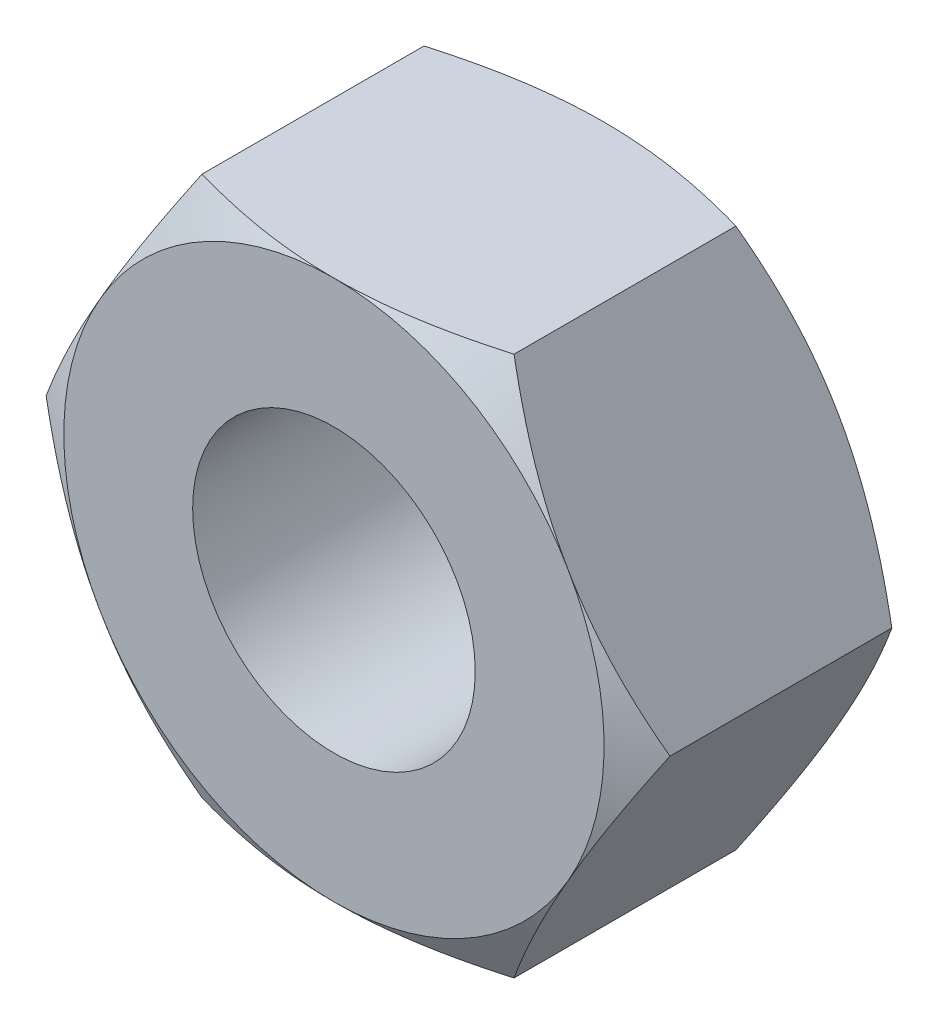
from build123d import *

# Parameters (mm, degrees)
BOSS_EXTRUDE1_DEPTH = 6.5
M8_TAPPED_HOLE1_D   = 6.8


with BuildPart() as part:
    # Sketch1 → Boss-Extrude1 (new body)
    with BuildSketch(Plane.XY):
        Polygon((3.75277675, -6.5), (7.505553499, 0), (3.75277675, 6.5), (-3.75277675, 6.5), (-7.505553499, 0), (-3.75277675, -6.5), align=None)
    extrude(amount=BOSS_EXTRUDE1_DEPTH)

    # Sketch3 → Cut-Revolve1 (revolve, cut)
    with BuildSketch(Plane(origin=(0, 0, 0), x_dir=(0, 0, -1), z_dir=(1, 0, 0))):
        Polygon((-1.711637245, 9.464642673), (0, 6.5), (0, 9.464642673), align=None)
        Polygon((-6.5, 6.5), (-6.5, 9.37662807), (-4.839178009, 9.37662807), align=None)
    revolve(axis=Axis((0, 0, 0), (0, 0, -1)), mode=Mode.SUBTRACT)

    # M8 Tapped Hole1 (through all)
    with Locations(Plane.XY.offset(6.5)):
        with Locations((0, 0)):
            Hole(M8_TAPPED_HOLE1_D / 2)


solid = part.part
